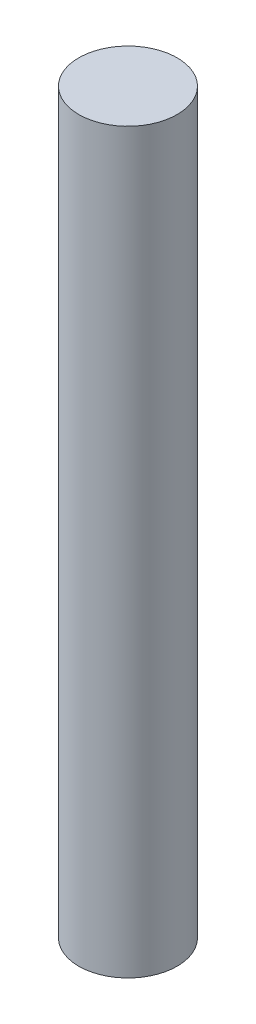
from build123d import *

# Parameters (mm, degrees)
SKETCH1_R           = 5
BOSS_EXTRUDE1_DEPTH = 37.5


with BuildPart() as part:
    # Sketch1 → Boss-Extrude1 (new body, symmetric)
    with BuildSketch(Plane(origin=(0, 0, 0), x_dir=(1, 0, 0), z_dir=(0, 1, 0))):
        Circle(SKETCH1_R)
    extrude(amount=BOSS_EXTRUDE1_DEPTH, both=True)


solid = part.part
